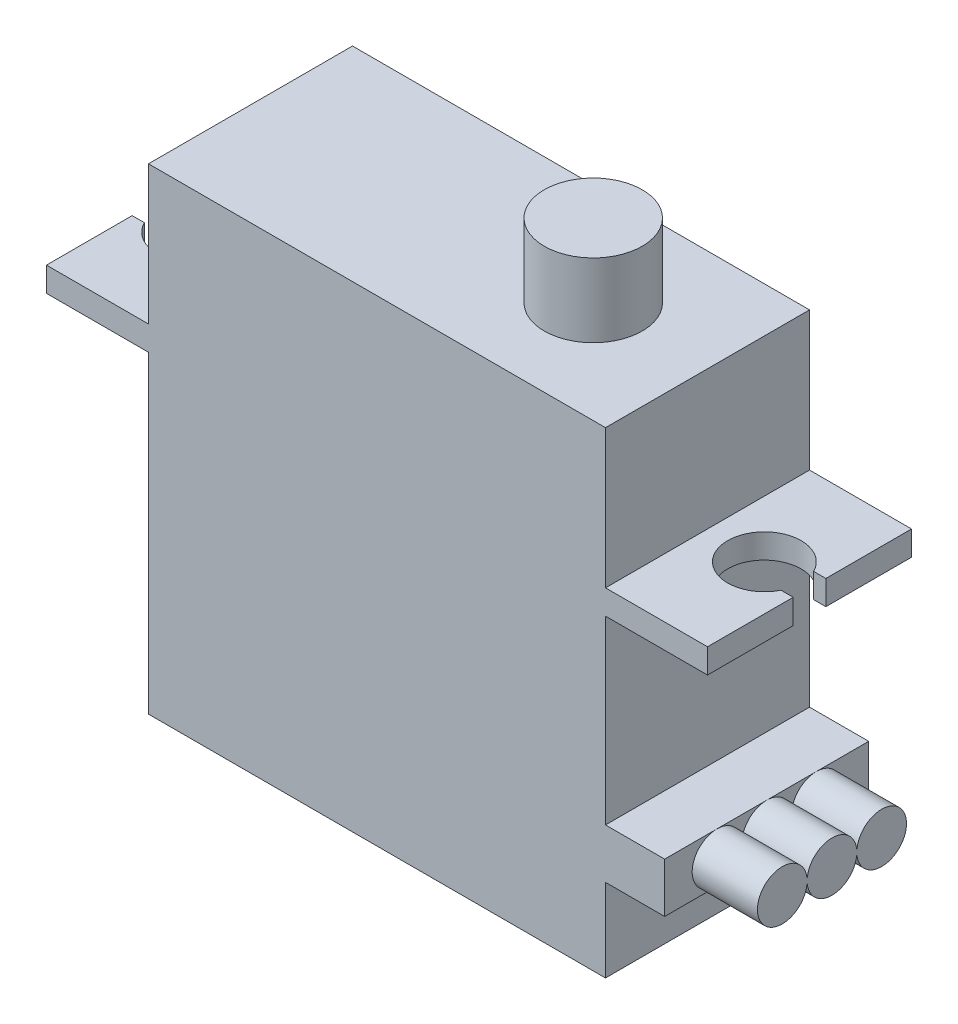
from build123d import *

# Parameters (mm, degrees)
BOSS_EXTRUDE1_DEPTH = 1.5
SKETCH2_W           = 28
SKETCH2_H           = 12.5
BOSS_EXTRUDE2_DEPTH = 8.5
SKETCH3_R           = 3
BOSS_EXTRUDE3_DEPTH = 4.5
SKETCH4_W           = 28
SKETCH4_H           = 12.5
BOSS_EXTRUDE4_DEPTH = 19.2
SKETCH5_W           = 3.625016777
SKETCH5_H           = 3.044537311
BOSS_EXTRUDE5_DEPTH = 12.5
BOSS_EXTRUDE7_DEPTH = 4


with BuildPart() as part:
    # Sketch1 → Boss-Extrude1 (new body)
    with BuildSketch(Plane(origin=(0, 0, 0), x_dir=(1, 0, 0), z_dir=(0, 1, 0))):
        with BuildLine():
            Line((20.25, -6.25), (-20.25, -6.25))
            Line((-20.25, -6.25), (-20.25, -1))
            Line((-20.25, -1), (-19.5, -1))
            ThreePointArc((-19.5, -1), (-15.234435563, 0), (-19.5, 1))
            Line((-19.5, 1), (-20.25, 1))
            Line((-20.25, 1), (-20.25, 6.25))
            Line((-20.25, 6.25), (20.25, 6.25))
            Line((20.25, 6.25), (20.25, 1))
            Line((20.25, 1), (19.5, 1))
            ThreePointArc((19.5, 1), (15.234435563, 0), (19.5, -1))
            Line((19.5, -1), (20.25, -1))
            Line((20.25, -1), (20.25, -6.25))
        make_face()
    extrude(amount=BOSS_EXTRUDE1_DEPTH)

    # Sketch2 → Boss-Extrude2 (add)
    with BuildSketch(Plane(origin=(0, 1.5, 0), x_dir=(1, 0, 0), z_dir=(0, 1, 0))):
        Rectangle(SKETCH2_W, SKETCH2_H)
    extrude(amount=BOSS_EXTRUDE2_DEPTH)

    # Sketch3 → Boss-Extrude3 (add)
    with BuildSketch(Plane(origin=(0, 10, 0), x_dir=(1, 0, 0), z_dir=(0, 1, 0))):
        with Locations((7, 0)):
            Circle(SKETCH3_R)
    extrude(amount=BOSS_EXTRUDE3_DEPTH)

    # Sketch4 → Boss-Extrude4 (add)
    with BuildSketch(Plane.XZ):
        Rectangle(SKETCH4_W, SKETCH4_H)
    extrude(amount=BOSS_EXTRUDE4_DEPTH)

    # Sketch5 → Boss-Extrude5 (add)
    with BuildSketch(Plane.XY.offset(6.25)):
        with Locations((15.812508389, -12.601527977)):
            Rectangle(SKETCH5_W, SKETCH5_H)
    extrude(amount=-BOSS_EXTRUDE5_DEPTH)

    # Sketch6 → Boss-Extrude7 (add)
    with BuildSketch(Plane(origin=(17.625016777, 0, 0), x_dir=(0, 0, -1), z_dir=(1, 0, 0))):
        with BuildLine():
            Line((-1.532511857, -12.7778257), (-1.512025454, -12.7778257))
            ThreePointArc((-1.512025454, -12.7778257), (0, -14.123796632), (1.512025454, -12.7778257))
            Line((1.512025454, -12.7778257), (1.532511857, -12.7778257))
            ThreePointArc((1.532511857, -12.7778257), (4.566805966, -12.601527977), (1.532511857, -12.425230254))
            Line((1.532511857, -12.425230254), (1.512025454, -12.425230254))
            ThreePointArc((1.512025454, -12.425230254), (0, -11.079259321), (-1.512025454, -12.425230254))
            Line((-1.512025454, -12.425230254), (-1.532511857, -12.425230254))
            ThreePointArc((-1.532511857, -12.425230254), (-4.566805966, -12.601527977), (-1.532511857, -12.7778257))
        make_face()
    extrude(amount=BOSS_EXTRUDE7_DEPTH)


solid = part.part
